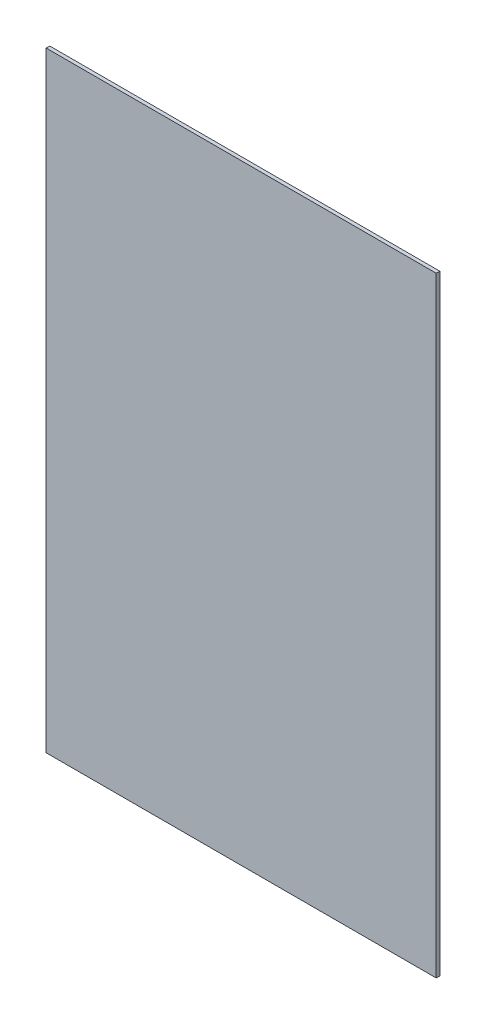
from build123d import *

# Parameters (mm, degrees)
SKETCH1_W           = 1092.111204978
SKETCH1_H           = 1709.008591034
BOSS_EXTRUDE1_DEPTH = 10


with BuildPart() as part:
    # Sketch1 → Boss-Extrude1 (new body)
    with BuildSketch(Plane.XY):
        with Locations((-12039.816174421, 8916.644075217)):
            Rectangle(SKETCH1_W, SKETCH1_H)
    extrude(amount=BOSS_EXTRUDE1_DEPTH)


solid = part.part
